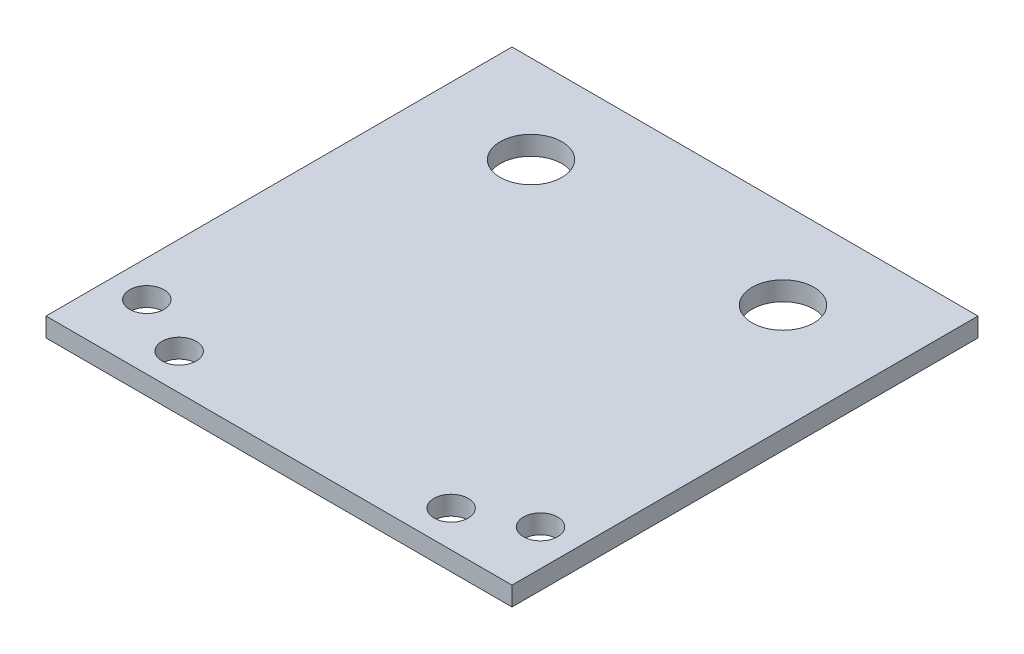
from build123d import *

# Parameters (mm, degrees)
SKETCH1_W               = 245
SKETCH1_H               = 245
BOSS_EXTRUDE1_DEPTH     = 5
SKETCH2_R               = 16.25
CUT_EXTRUDE1_DEPTH      = 10
SKETCH3_R               = 9
CUT_EXTRUDE2_DEPTH      = 10
CUT_EXTRUDE3_DEPTH      = 174.313300124
CUT_EXTRUDE3_DEPTH_BACK = 174.313300124
SKETCH3_3_R             = 9


with BuildPart() as part:
    # Sketch1 → Boss-Extrude1 (new, symmetric)
    with BuildSketch(Plane(origin=(0, 0, 0), x_dir=(1, 0, 0), z_dir=(0, 1, 0))):
        Rectangle(SKETCH1_W, SKETCH1_H)
    extrude(amount=BOSS_EXTRUDE1_DEPTH, both=True)

    # Sketch2 → Cut-Extrude1 (cut)
    with BuildSketch(Plane(origin=(0, 5, 0), x_dir=(1, 0, 0), z_dir=(0, 1, 0))):
        with Locations((-66.25, 76.25)):
            Circle(SKETCH2_R)
        with Locations((66.25, 76.25)):
            Circle(SKETCH2_R)
    extrude(amount=-CUT_EXTRUDE1_DEPTH, mode=Mode.SUBTRACT)

    # Sketch3 → Cut-Extrude2 (cut)
    with BuildSketch(Plane(origin=(0, 0, 0), x_dir=(1, 0, 0), z_dir=(0, 1, 0))):
        with Locations((71.5, -103.5)):
            Circle(SKETCH3_R)
    extrude(amount=-CUT_EXTRUDE2_DEPTH, mode=Mode.SUBTRACT)

    # Sketch3_3 → Cut-Extrude3 (cut, two sides: drawn at the far end of the back side and taken through both)
    with BuildSketch(Plane(origin=(0, 0, 0), x_dir=(1, 0, 0), z_dir=(0, 1, 0)).offset(-CUT_EXTRUDE3_DEPTH_BACK)):
        with Locations((103.5, -88.5)):
            Circle(SKETCH3_3_R)
        with Locations((71.5, -103.5)):
            Circle(SKETCH3_3_R)
        with Locations((-71.5, -103.5)):
            Circle(SKETCH3_3_R)
        with Locations((-103.5, -88.5)):
            Circle(SKETCH3_3_R)
    extrude(amount=CUT_EXTRUDE3_DEPTH + CUT_EXTRUDE3_DEPTH_BACK, mode=Mode.SUBTRACT)


solid = part.part
